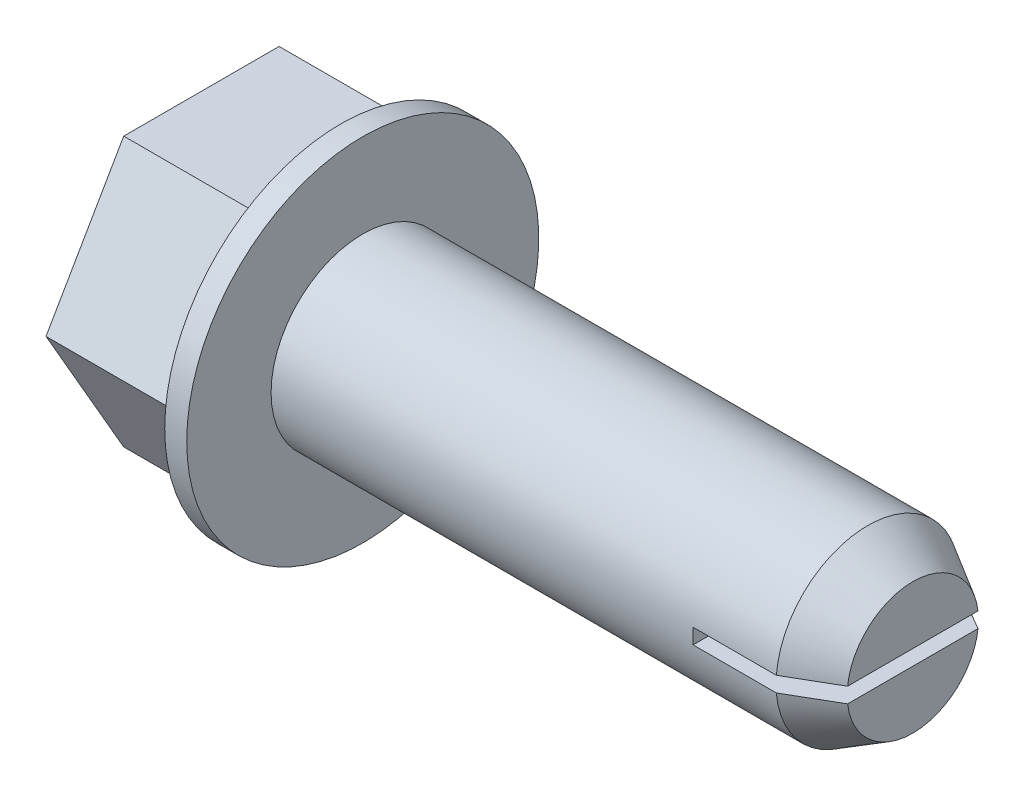
from build123d import *

# Parameters (mm, degrees)
EXTRUDE1_REACH                 = 26.638
SKETCH13_W                     = 4.445
SKETCH13_H                     = 0.529166666
POINT_CUT_EXTRUDE10_DEPTH      = 7.096
POINT_CUT_EXTRUDE10_DEPTH_BACK = 7.096


with BuildPart() as part:
    # Sketch1 → base-Revolve (revolve)
    with BuildSketch(Plane.XY):
        Polygon((0, 6.096), (-0.762, 6.096), (-0.762, 4.6609), (-5.588, 4.6609), (-5.588, 3.72872), (-4.6228, 3.72872), (-4.6228, 0), (0, 0), (19.05, 0), (19.05, 3.175), (0, 3.175), align=None)
    revolve(axis=Axis((0, 0, 0), (1, 0, 0)))

    # Sketch15 → Extrude1 (add, up to next)
    with BuildSketch(Plane.ZY.offset(5.588), mode=Mode.PRIVATE) as extrude1_sk1:
        with BuildLine():
            ThreePointArc((-4.036457824, -2.330449967), (-4.6609, 3.6e-08), (-4.036457787, 2.33045003))
            Line((-4.036457787, 2.33045003), (-5.381943739, 0))
            Line((-5.381943739, 0), (-4.036457824, -2.330449967))
        make_face()
    extrude1_tool1 = extrude(extrude1_sk1.sketch, amount=-EXTRUDE1_REACH, mode=Mode.PRIVATE) - part.part
    add(extrude1_tool1.solids().sort_by_distance((-5.588, 0, -4.817334))[0])
    # Sketch15 → Extrude1 (add, up to next)
    with BuildSketch(Plane.ZY.offset(5.588), mode=Mode.PRIVATE) as extrude1_sk2:
        with BuildLine():
            ThreePointArc((-4.036457787, 2.33045003), (-2.330449985, 4.036457813), (0, 4.6609))
            Line((0, 4.6609), (-2.69097187, 4.6609))
            Line((-2.69097187, 4.6609), (-4.036457787, 2.33045003))
        make_face()
    extrude1_tool2 = extrude(extrude1_sk2.sketch, amount=-EXTRUDE1_REACH, mode=Mode.PRIVATE) - part.part
    add(extrude1_tool2.solids().sort_by_distance((-5.588, 4.171933, -2.408667))[0])
    # Sketch15 → Extrude1 (add, up to next)
    with BuildSketch(Plane.ZY.offset(5.588), mode=Mode.PRIVATE) as extrude1_sk3:
        with BuildLine():
            ThreePointArc((0, 4.6609), (2.330450001, 4.036457804), (4.036457805, 2.330449998))
            Line((4.036457805, 2.330449998), (2.69097187, 4.6609))
            Line((2.69097187, 4.6609), (0, 4.6609))
        make_face()
    extrude1_tool3 = extrude(extrude1_sk3.sketch, amount=-EXTRUDE1_REACH, mode=Mode.PRIVATE) - part.part
    add(extrude1_tool3.solids().sort_by_distance((-5.588, 4.171933, 2.408667))[0])
    # Sketch15 → Extrude1 (add, up to next)
    with BuildSketch(Plane.ZY.offset(5.588), mode=Mode.PRIVATE) as extrude1_sk4:
        with BuildLine():
            Line((4.036457776, -2.330450049), (5.381943739, 0))
            Line((5.381943739, 0), (4.036457805, 2.330449998))
            ThreePointArc((4.036457805, 2.330449998), (4.502083684, 1.206329686), (4.6609, 0))
            ThreePointArc((4.6609, 0), (4.502083676, -1.206329715), (4.036457776, -2.330450049))
        make_face()
    extrude1_tool4 = extrude(extrude1_sk4.sketch, amount=-EXTRUDE1_REACH, mode=Mode.PRIVATE) - part.part
    add(extrude1_tool4.solids().sort_by_distance((-5.588, 0, 4.817334))[0])
    # Sketch15 → Extrude1 (add, up to next)
    with BuildSketch(Plane.ZY.offset(5.588), mode=Mode.PRIVATE) as extrude1_sk5:
        with BuildLine():
            Line((2.69097187, -4.6609), (4.036457776, -2.330450049))
            ThreePointArc((4.036457776, -2.330450049), (2.330449975, -4.036457819), (0, -4.6609))
            Line((0, -4.6609), (2.69097187, -4.6609))
        make_face()
    extrude1_tool5 = extrude(extrude1_sk5.sketch, amount=-EXTRUDE1_REACH, mode=Mode.PRIVATE) - part.part
    add(extrude1_tool5.solids().sort_by_distance((-5.588, -4.171933, 2.408667))[0])
    # Sketch15 → Extrude1 (add, up to next)
    with BuildSketch(Plane.ZY.offset(5.588), mode=Mode.PRIVATE) as extrude1_sk6:
        with BuildLine():
            Line((-2.69097187, -4.6609), (0, -4.6609))
            ThreePointArc((0, -4.6609), (-2.330450017, -4.036457795), (-4.036457824, -2.330449967))
            Line((-4.036457824, -2.330449967), (-2.69097187, -4.6609))
        make_face()
    extrude1_tool6 = extrude(extrude1_sk6.sketch, amount=-EXTRUDE1_REACH, mode=Mode.PRIVATE) - part.part
    add(extrude1_tool6.solids().sort_by_distance((-5.588, -4.171933, -2.408667))[0])

    # Sketch8 → point_Cut-Revolve1 (revolve, cut)
    with BuildSketch(Plane.XY):
        Polygon((19.05, 0), (19.558, 0), (19.558, 3.683), (17.488209787, 3.683), (17.488209787, 3.175), (19.05, 2.2733), align=None)
    revolve(axis=Axis((0, 0, 0), (1, 0, 0)), mode=Mode.SUBTRACT)

    # Sketch13 → point_Cut-Extrude10 (cut, two sides)
    with BuildSketch(Plane.XY) as point_cut_extrude10_sk:
        with Locations((16.8275, 0)):
            Rectangle(SKETCH13_W, SKETCH13_H)
    extrude(amount=POINT_CUT_EXTRUDE10_DEPTH, mode=Mode.SUBTRACT)
    extrude(point_cut_extrude10_sk.sketch, amount=-POINT_CUT_EXTRUDE10_DEPTH_BACK, mode=Mode.SUBTRACT)


solid = part.part
